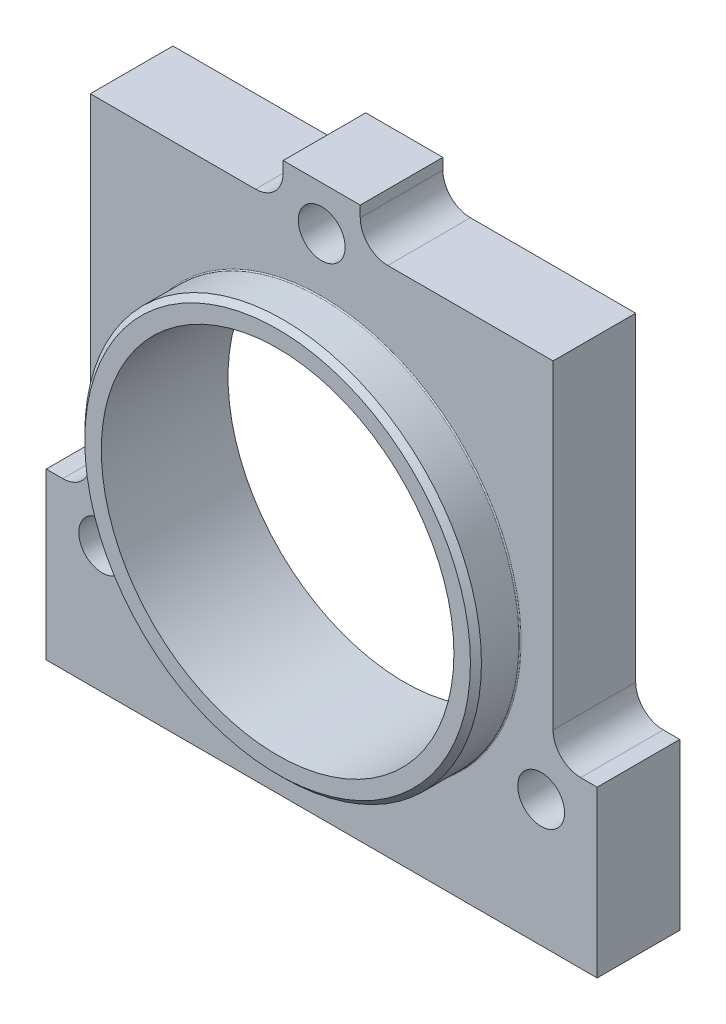
from build123d import *

# Parameters (mm, degrees)
ESQUISSE1_R                  = 32
BOSS_EXTRU_1_DEPTH           = 15
ESQUISSE2_R                  = 36
ESQUISSE2_R_2                = 32
BOSS_EXTRU_2_DEPTH           = 8
CHANFREIN1_SIZE              = 1
CONG_1_R                     = 0.2
ESQUISSE3_R                  = 4.25
ENL_V_MAT_EXTRU_1_DEPTH      = 24
ESQUISSE4_R                  = 7
ENL_V_MAT_EXTRU_2_DEPTH      = 8
R_P_TITION_CIRCULAIRE1_COUNT = 3


with BuildPart() as part:
    # Esquisse1 → Boss.-Extru.1 (new body)
    with BuildSketch(Plane.XY):
        with BuildLine():
            Line((-7, 54), (7, 54))
            Line((7, 54), (7, 52))
            ThreePointArc((7, 52), (8.464466094, 48.464466094), (12, 47))
            Line((12, 47), (42, 47))
            Line((42, 47), (42, -11))
            ThreePointArc((42, -11), (43.464466094, -14.535533906), (47, -16))
            Line((47, -16), (50, -16))
            Line((50, -16), (50, -46))
            Line((50, -46), (-50, -46))
            Line((-50, -46), (-50, -16))
            Line((-50, -16), (-47, -16))
            ThreePointArc((-47, -16), (-43.464466094, -14.535533906), (-42, -11))
            Line((-42, -11), (-42, 47))
            Line((-42, 47), (-12, 47))
            ThreePointArc((-12, 47), (-8.464466094, 48.464466094), (-7, 52))
            Line((-7, 52), (-7, 54))
        make_face()
        Circle(ESQUISSE1_R, mode=Mode.SUBTRACT)
    extrude(amount=BOSS_EXTRU_1_DEPTH)

    # Esquisse2 → Boss.-Extru.2 (add)
    with BuildSketch(Plane.XY.offset(15)):
        with Locations(Location((0, 0, 0), (0, 0, 180))):  # turned: the seam where the file's is
            Circle(ESQUISSE2_R)
        Circle(ESQUISSE2_R_2, mode=Mode.SUBTRACT)
    extrude(amount=BOSS_EXTRU_2_DEPTH)

    # Chanfrein1
    chanfrein1_edges = [part.edges().sort_by_distance(p)[0] for p in [
        (36, 0, 23),
    ]]
    chamfer(chanfrein1_edges, length=CHANFREIN1_SIZE)

    # Congé1
    cong_1_edges = [part.edges().sort_by_distance(p)[0] for p in [
        (36, 0, 15),
    ]]
    fillet(cong_1_edges, radius=CONG_1_R)

    # Esquisse3 → Enlèv. mat.-Extru.1 (cut, through all)
    with BuildSketch(Plane(origin=(0, 0, 0), x_dir=(-1, 0, 0), z_dir=(0, 0, -1))):
        with Locations((0, 46)):
            Circle(ESQUISSE3_R)
    enl_v_mat_extru_1 = extrude(amount=-ENL_V_MAT_EXTRU_1_DEPTH, mode=Mode.SUBTRACT)

    # Esquisse4 → Enlèv. mat.-Extru.2 (cut)
    with BuildSketch(Plane(origin=(0, 0, 0), x_dir=(-1, 0, 0), z_dir=(0, 0, -1))):
        with Locations((0, 46)):
            Circle(ESQUISSE4_R)
    enl_v_mat_extru_2 = extrude(amount=-ENL_V_MAT_EXTRU_2_DEPTH, mode=Mode.SUBTRACT)

    # Répétition circulaire1: Enlèv. mat.-Extru.1, Enlèv. mat.-Extru.2 ×3 about axis
    r_p_tition_circulaire1_axis = Axis((0, 0, 0), (0, 0, 1))
    add([enl_v_mat_extru_1.rotate(r_p_tition_circulaire1_axis, i * 360 / R_P_TITION_CIRCULAIRE1_COUNT) for i in range(1, R_P_TITION_CIRCULAIRE1_COUNT)], mode=Mode.SUBTRACT)
    add([enl_v_mat_extru_2.rotate(r_p_tition_circulaire1_axis, i * 360 / R_P_TITION_CIRCULAIRE1_COUNT) for i in range(1, R_P_TITION_CIRCULAIRE1_COUNT)], mode=Mode.SUBTRACT)


solid = part.part
